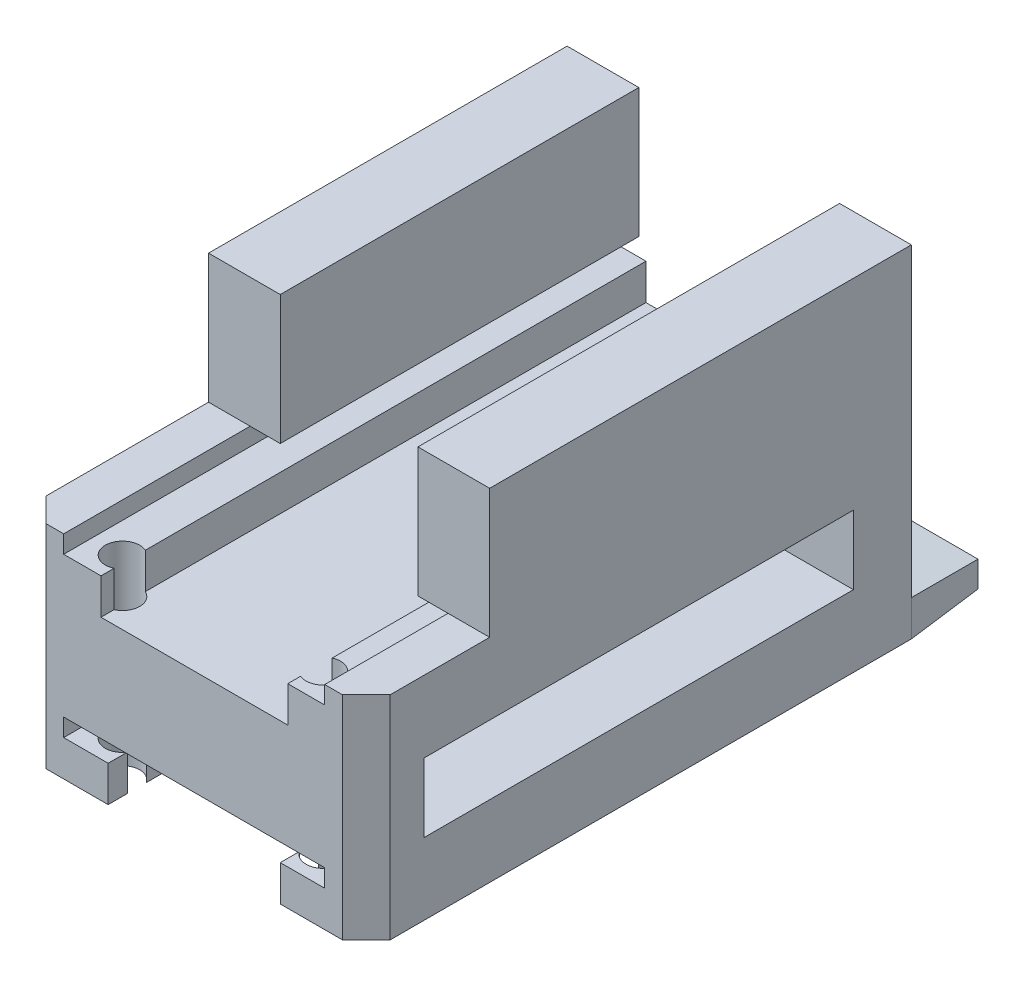
from build123d import *

# Parameters (mm, degrees)
SKETCH1_W                     = 30.48
SKETCH1_H                     = 50.8
SKETCH1_R                     = 1.524
BOSS_EXTRUDE1_DEPTH           = 12.7
CUT_EXTRUDE1_DEPTH            = 55.536112806
SKETCH3_W                     = 13.253769435
SKETCH3_H                     = 10.922
CUT_EXTRUDE2_DEPTH            = 6.35
SKETCH4_W                     = 23.114
SKETCH4_H                     = 19.05
CUT_EXTRUDE3_DEPTH            = 3.175
CUT_EXTRUDE4_DEPTH            = 2.54
SKETCH7_W                     = 3.272
SKETCH7_H                     = 3.175
SKETCH7_W_2                   = 3.302
BOSS_EXTRUDE2_DEPTH           = 16.51
SKETCH8_W                     = 16.54
SKETCH8_H                     = 3.175
CUT_EXTRUDE5_DEPTH            = 38.438083551
CUT_EXTRUDE5_DEPTH_BACK       = 38.438083551
SKETCH9_W                     = 30.48
SKETCH9_H                     = 5.13
SKETCH9_R                     = 1.524
BOSS_EXTRUDE3_DEPTH           = 6.1
SKETCH10_W                    = 30.48
SKETCH10_H                    = 48.26
SKETCH10_R                    = 1.524
BOSS_EXTRUDE4_DEPTH           = 6.35
CUT_EXTRUDE7_DEPTH            = 53.178302004
CUT_EXTRUDE7_DEPTH_BACK       = 53.178302004
BOSS_EXTRUDE5_DEPTH           = 6.35
BOSS_EXTRUDE5_DRAFT           = 4
BOSS_EXTRUDE5_PROFILE_2_DEPTH = 6.35
BOSS_EXTRUDE5_PROFILE_2_DRAFT = 4
CUT_EXTRUDE8_DEPTH            = 42.448814217
SKETCH14_W                    = 6.35
SKETCH14_H                    = 31.75
SKETCH14_H_2                  = 37.338
BOSS_EXTRUDE6_DEPTH           = 5.08


with BuildPart() as part:
    # Sketch1 → Boss-Extrude1 (new body)
    with BuildSketch(Plane(origin=(0, 0, 0), x_dir=(1, 0, 0), z_dir=(0, 1, 0))):
        Rectangle(SKETCH1_W, SKETCH1_H)
        with Locations(Location((8.89, -22.86, 0), (0, 0, 270))):
            Circle(SKETCH1_R, mode=Mode.SUBTRACT)
        with Locations(Location((-8.89, -22.86, 0), (0, 0, 270))):
            Circle(SKETCH1_R, mode=Mode.SUBTRACT)
        with Locations((8.89, 22.86)):
            Circle(SKETCH1_R, mode=Mode.SUBTRACT)
        with Locations((-8.89, 22.86)):
            Circle(SKETCH1_R, mode=Mode.SUBTRACT)
        with Locations((8.89, 22.86)):
            Circle(SKETCH1_R)
        with Locations((-8.89, 22.86)):
            Circle(SKETCH1_R)
    extrude(amount=BOSS_EXTRUDE1_DEPTH)

    # Sketch2 → Cut-Extrude1 (cut, through all)
    with BuildSketch(Plane.XY.offset(25.4)):
        Polygon((8.89, 12.7), (-8.89, 12.7), (-8.89, 6.35), (-11.557, 6.35), (-11.557, 4.78), (11.557, 4.78), (11.557, 6.35), (8.89, 6.35), align=None)
    extrude(amount=-CUT_EXTRUDE1_DEPTH, mode=Mode.SUBTRACT)

    # Sketch3 → Cut-Extrude2 (cut)
    with BuildSketch(Plane(origin=(0, 12.7, 0), x_dir=(1, 0, 0), z_dir=(0, 1, 0))):
        Polygon((-15.24, -8.89), (-15.24, -25.4), (1.986230565, -25.4), (1.986230565, -14.478), (1.986230565, -8.89), align=None)
        with Locations((8.613115283, -19.939)):
            Rectangle(SKETCH3_W, SKETCH3_H)
    extrude(amount=-CUT_EXTRUDE2_DEPTH, mode=Mode.SUBTRACT)

    # Sketch4 → Cut-Extrude3 (cut)
    with BuildSketch(Plane(origin=(0, 4.78, 0), x_dir=(1, 0, 0), z_dir=(0, 1, 0))):
        with Locations((0, 15.875)):
            Rectangle(SKETCH4_W, SKETCH4_H)
    extrude(amount=-CUT_EXTRUDE3_DEPTH, mode=Mode.SUBTRACT)

    # Sketch6 → Cut-Extrude4 (cut)
    with BuildSketch(Plane(origin=(0, 0, -25.4), x_dir=(-1, 0, 0), z_dir=(0, 0, -1))):
        Polygon((11.557, 6.35), (11.557, 1.605), (-11.557, 1.605), (-11.557, 6.35), (-8.89, 6.35), (-8.89, 12.7), (-15.24, 12.7), (-15.24, 0), (15.24, 0), (15.24, 12.7), (8.89, 12.7), (8.89, 6.35), align=None)
    extrude(amount=-CUT_EXTRUDE4_DEPTH, mode=Mode.SUBTRACT)

    # Sketch7 → Boss-Extrude2 (add)
    with BuildSketch(Plane(origin=(0, 0, -6.35), x_dir=(-1, 0, 0), z_dir=(0, 0, -1))):
        with Locations((-9.921, 3.1925)):
            Rectangle(SKETCH7_W, SKETCH7_H)
        with Locations((9.906, 3.1925)):
            Rectangle(SKETCH7_W_2, SKETCH7_H)
    extrude(amount=BOSS_EXTRUDE2_DEPTH)

    # Sketch8 → Cut-Extrude5 (cut, two sides)
    with BuildSketch(Plane(origin=(0, 0, -6.35), x_dir=(-1, 0, 0), z_dir=(0, 0, -1))) as cut_extrude5_sk:
        with Locations((-0.015, 3.1925)):
            Rectangle(SKETCH8_W, SKETCH8_H)
    extrude(amount=CUT_EXTRUDE5_DEPTH, mode=Mode.SUBTRACT)
    extrude(cut_extrude5_sk.sketch, amount=-CUT_EXTRUDE5_DEPTH_BACK, mode=Mode.SUBTRACT)

    # Sketch9 → Boss-Extrude3 (add)
    with BuildSketch(Plane.XZ):
        with Locations((0, 22.835)):
            Rectangle(SKETCH9_W, SKETCH9_H)
        with Locations(Location((-8.89, 22.86, 0), (0, 0, 270))):
            Circle(SKETCH9_R, mode=Mode.SUBTRACT)
        with Locations(Location((8.89, 22.86, 0), (0, 0, 270))):
            Circle(SKETCH9_R, mode=Mode.SUBTRACT)
        with Locations((0, -20.295)):
            Rectangle(SKETCH9_W, SKETCH9_H)
    extrude(amount=BOSS_EXTRUDE3_DEPTH)

    # Sketch10 → Boss-Extrude4 (add)
    with BuildSketch(Plane.XZ.offset(6.1)):
        with Locations((0, 1.27)):
            Rectangle(SKETCH10_W, SKETCH10_H)
        with Locations(Location((8.89, 22.86, 0), (0, 0, 270))):
            Circle(SKETCH10_R, mode=Mode.SUBTRACT)
        with Locations(Location((-8.89, 22.86, 0), (0, 0, 270))):
            Circle(SKETCH10_R, mode=Mode.SUBTRACT)
    extrude(amount=BOSS_EXTRUDE4_DEPTH)

    # Sketch11 → Cut-Extrude7 (cut, two sides)
    with BuildSketch(Plane.XY.offset(25.4)) as cut_extrude7_sk:
        Polygon((-7.62, -12.45), (0, -12.45), (0, -7.7002), (-11.557, -7.7002), (-11.557, -9.275), (-7.62, -9.275), align=None)
        Polygon((0, -7.7002), (0, -12.45), (7.62, -12.45), (7.62, -9.275), (11.557, -9.275), (11.557, -7.7002), align=None)
    extrude(amount=CUT_EXTRUDE7_DEPTH, mode=Mode.SUBTRACT)
    extrude(cut_extrude7_sk.sketch, amount=-CUT_EXTRUDE7_DEPTH_BACK, mode=Mode.SUBTRACT)


with BuildPart() as boss_extrude5_tool:
    # Sketch12 → Boss-Extrude5 (with draft: the straight prism first)
    with BuildSketch(Plane(origin=(0, 0, -22.86), x_dir=(-1, 0, 0), z_dir=(0, 0, -1))):
        Polygon((-7.62, -12.45), (-7.62, -9.275), (-11.557, -9.275), (-15.24, -9.275), (-15.24, -12.45), align=None)
    extrude(amount=BOSS_EXTRUDE5_DEPTH)
    # Boss-Extrude5: the draft: its side faces are tilted about the plane it starts from
    boss_extrude5_sides = [boss_extrude5_tool.faces().sort_by_distance(p)[0] for p in [
        (7.62, -10.8625, -26.035),
        (15.24, -10.8625, -26.035),
        (11.43, -9.275, -26.035),
        (11.43, -12.45, -26.035),
    ]]
    draft(boss_extrude5_sides, Plane(origin=(0, 0, -22.86), x_dir=(-1, 0, 0), z_dir=(0, 0, -1)), BOSS_EXTRUDE5_DRAFT)


with BuildPart() as part_1:
    add(part.part)

    # Boss-Extrude5: add boss_extrude5_tool
    add(boss_extrude5_tool.part)


with BuildPart() as boss_extrude5_profile_2_tool:
    # Sketch12 → Boss-Extrude5 profile 2 (with draft: the straight prism first)
    with BuildSketch(Plane(origin=(0, 0, -22.86), x_dir=(-1, 0, 0), z_dir=(0, 0, -1))):
        Polygon((15.24, -12.45), (15.24, -9.275), (11.557, -9.275), (7.62, -9.275), (7.62, -12.45), align=None)
    extrude(amount=BOSS_EXTRUDE5_PROFILE_2_DEPTH)
    # Boss-Extrude5 profile 2: the draft: its side faces are tilted about the plane it starts from
    boss_extrude5_profile_2_sides = [boss_extrude5_profile_2_tool.faces().sort_by_distance(p)[0] for p in [
        (-11.43, -12.45, -26.035),
        (-11.43, -9.275, -26.035),
        (-15.24, -10.8625, -26.035),
        (-7.62, -10.8625, -26.035),
    ]]
    draft(boss_extrude5_profile_2_sides, Plane(origin=(0, 0, -22.86), x_dir=(-1, 0, 0), z_dir=(0, 0, -1)), BOSS_EXTRUDE5_PROFILE_2_DRAFT)


with BuildPart() as part_2:
    add(part_1.part)

    # Boss-Extrude5 profile 2: add boss_extrude5_profile_2_tool
    add(boss_extrude5_profile_2_tool.part)

    # Sketch13 → Cut-Extrude8 (cut, through all)
    with BuildSketch(Plane.XZ.offset(12.45)):
        Polygon((-22.129268927, 18.728628624), (-23.925320151, 20.524679849), (-15.843089642, 28.606910358), (-14.047038418, 26.810859133), (-11.837895412, 29.020002139), (-10.670462117, 27.852568843), (-23.170978637, 15.352052323), (-24.338411933, 16.519485619), align=None)
        Polygon((23.170978637, 15.352052323), (24.338411933, 16.519485619), (22.129268927, 18.728628624), (23.925320151, 20.524679849), (15.843089642, 28.606910358), (14.047038418, 26.810859133), (11.837895412, 29.020002139), (10.670462117, 27.852568843), (13.12303096, 25.4), (15.24, 25.4), (15.24, 23.28303096), align=None)
        Polygon((13.12303096, 25.4), (15.24, 23.28303096), (15.24, 25.4), align=None)
    extrude(amount=-CUT_EXTRUDE8_DEPTH, mode=Mode.SUBTRACT)

    # Sketch14 → Boss-Extrude6 (add)
    with BuildSketch(Plane(origin=(0, 12.7, 0), x_dir=(1, 0, 0), z_dir=(0, 1, 0))):
        with Locations((-12.065, 6.985)):
            Rectangle(SKETCH14_W, SKETCH14_H)
        with Locations((12.065, 4.191)):
            Rectangle(SKETCH14_W, SKETCH14_H_2)
    extrude(amount=BOSS_EXTRUDE6_DEPTH)


solid = part_2.part
